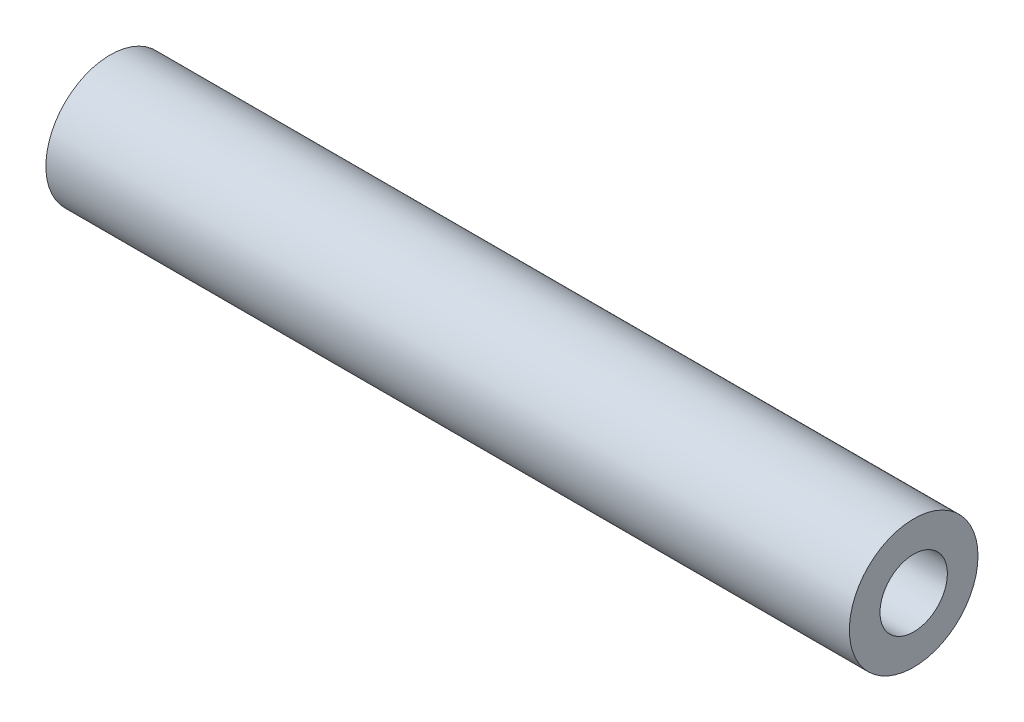
from build123d import *

# Parameters (mm, degrees)
SWEEP_THIN1_PROFILE_R   = 6.302
SWEEP_THIN1_PROFILE_R_2 = 3.302


with BuildPart() as part:
    # Sweep-Thin1: sweep along a path in Sketch1
    with BuildLine(Plane(origin=(0, 0, 0), x_dir=(1, 0, 0), z_dir=(0, 1, 0))) as sweep_thin1_path:
        Line((-86.194359401, -3.069936088), (-7.454359401, -3.069936088))
    # Sweep-Thin1 profile (on start of the path) → Sweep-Thin1 (sweep)
    with BuildSketch(Plane(origin=(-86.194359401, 0, 3.069936088), x_dir=(0, 0, 1), z_dir=(1, 0, 0))):
        Circle(SWEEP_THIN1_PROFILE_R)
        Circle(SWEEP_THIN1_PROFILE_R_2, mode=Mode.SUBTRACT)
    sweep(path=sweep_thin1_path.line)


solid = part.part
